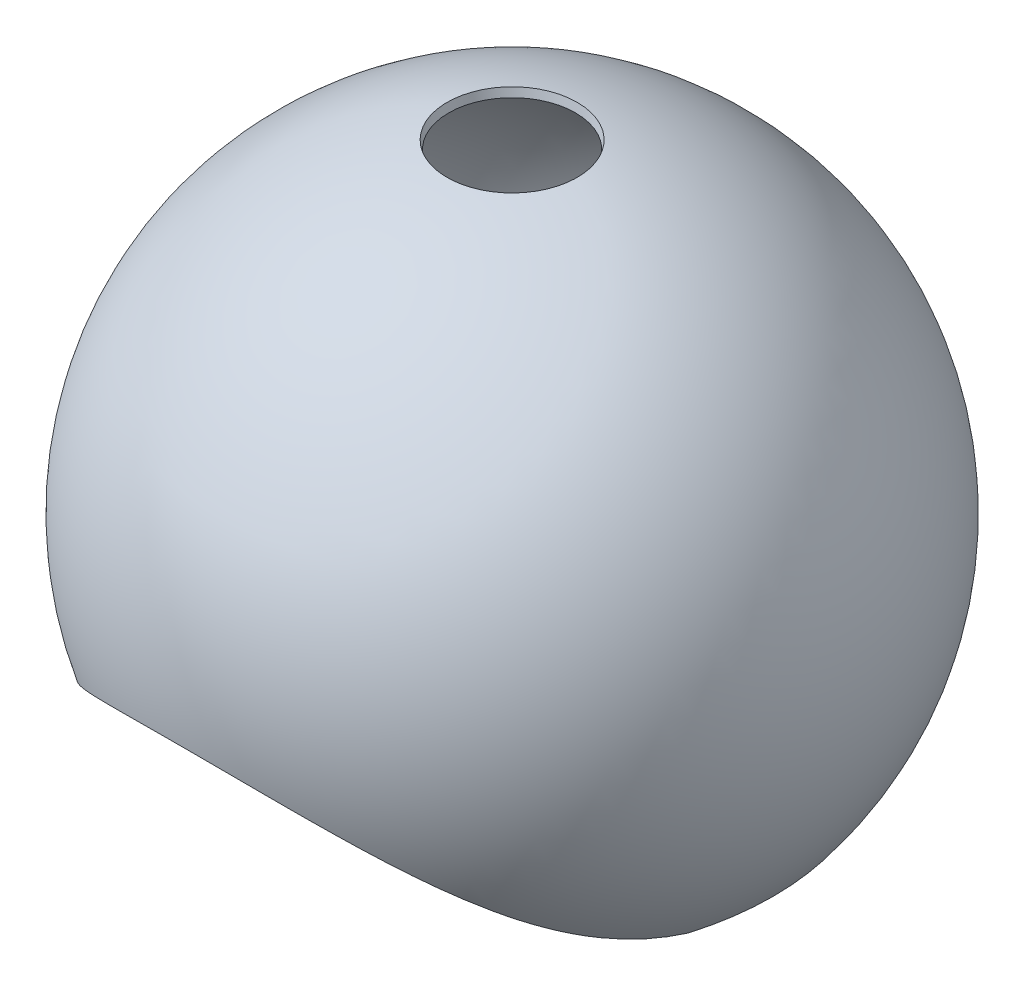
from build123d import *

# Parameters (mm, degrees)
SKETCH2_R                = 5
BOSS_EXTRUDE1_DEPTH      = 10
SKETCH5_R                = 2.4
CUT_EXTRUDE2_DEPTH       = 3
CUT_EXTRUDE5_DEPTH       = 190.620679457
CUT_EXTRUDE5_DEPTH_BACK  = 190.620679457
BOSS_EXTRUDE2_DEPTH      = 8
BOSS_EXTRUDE2_DEPTH_BACK = 10
SKETCH10_R               = 1.4
CUT_EXTRUDE6_DEPTH       = 8
BOSS_EXTRUDE3_START      = 6
SKETCH11_R               = 5
BOSS_EXTRUDE3_DEPTH      = 6
SKETCH12_R               = 5
SKETCH12_R_2             = 3
CUT_EXTRUDE8_DEPTH       = 1
SKETCH13_R               = 1.9
CUT_EXTRUDE9_DEPTH       = 5


with BuildPart() as part:
    # Sketch1 → Revolve1 (revolve)
    with BuildSketch(Plane.XY):
        with BuildLine():
            Line((-61.750890187, -47.653200953), (-59.204496779, -47.653200953))
            ThreePointArc((-59.204496779, -47.653200953), (-71.464924193, 25.860483564), (-15, 74.505033387))
            Line((-15, 74.505033387), (-15.394736842, 76.46569216))
            ThreePointArc((-15.394736842, 76.46569216), (-73.070081767, 27.290349038), (-61.750890187, -47.653200953))
        make_face()
    revolve(axis=Axis((0, 0, 0), (0, 1, 0)))

    # Sketch2 → Boss-Extrude1 (add)
    with BuildSketch(Plane.XY.offset(77)):
        Circle(SKETCH2_R)
    extrude(amount=-BOSS_EXTRUDE1_DEPTH)

    # Sketch5 → Cut-Extrude2 (cut)
    with BuildSketch(Plane(origin=(0, 0, 67), x_dir=(-1, 0, 0), z_dir=(0, 0, -1))):
        Circle(SKETCH5_R)
    extrude(amount=-CUT_EXTRUDE2_DEPTH, mode=Mode.SUBTRACT)

    # Sketch8 → Cut-Extrude5 (cut, two sides: drawn at the far end of the back side and taken through both)
    with BuildSketch(Plane.XY.offset(77).offset(-CUT_EXTRUDE5_DEPTH_BACK)):
        with BuildLine():
            Line((59.204496779, -47.653200953), (-59.204496779, -47.653200953))
            ThreePointArc((-59.204496779, -47.653200953), (0, -9.482803282), (59.204496779, -47.653200953))
        make_face()
    extrude(amount=CUT_EXTRUDE5_DEPTH + CUT_EXTRUDE5_DEPTH_BACK, mode=Mode.SUBTRACT)

    # Sketch9 → Boss-Extrude2 (add, two sides: drawn at the far end of the back side and taken through both)
    with BuildSketch(Plane(origin=(0, 0, 0), x_dir=(0, 0, -1), z_dir=(1, 0, 0)).offset(-BOSS_EXTRUDE2_DEPTH_BACK)):
        Polygon((-24.799638763, 42.367833372), (-18.503698204, 44.659368332), (-18.503698204, 74.505033387), (-27.09103143, 71.379499701), (-35.489739706, 67.690470627), (-39.978084848, 64.869225109), align=None)
    extrude(amount=BOSS_EXTRUDE2_DEPTH + BOSS_EXTRUDE2_DEPTH_BACK)

    # Sketch10 → Cut-Extrude6 (cut)
    with BuildSketch(Plane(origin=(0, 45.382188608, 16.517765819), x_dir=(1, 0, 0), z_dir=(0, -0.939692620785908, -0.34202014332567005))):
        with Locations((-4.00206731, 5.513385102)):
            Circle(SKETCH10_R)
        with Locations((2.39793269, 5.513385102)):
            Circle(SKETCH10_R)
    extrude(amount=-CUT_EXTRUDE6_DEPTH, mode=Mode.SUBTRACT)

    # Sketch11 → Boss-Extrude3 (add)
    with BuildSketch(Plane.XY.offset(-77).offset(BOSS_EXTRUDE3_START)):
        Circle(SKETCH11_R)
    extrude(amount=-BOSS_EXTRUDE3_DEPTH)

    # Sketch12 → Cut-Extrude8 (cut)
    with BuildSketch(Plane.XY.offset(-71)):
        Circle(SKETCH12_R)
        Circle(SKETCH12_R_2, mode=Mode.SUBTRACT)
    extrude(amount=-CUT_EXTRUDE8_DEPTH, mode=Mode.SUBTRACT)

    # Sketch13 → Cut-Extrude9 (cut)
    with BuildSketch(Plane.XY.offset(-71)):
        Circle(SKETCH13_R)
    extrude(amount=-CUT_EXTRUDE9_DEPTH, mode=Mode.SUBTRACT)


solid = part.part
